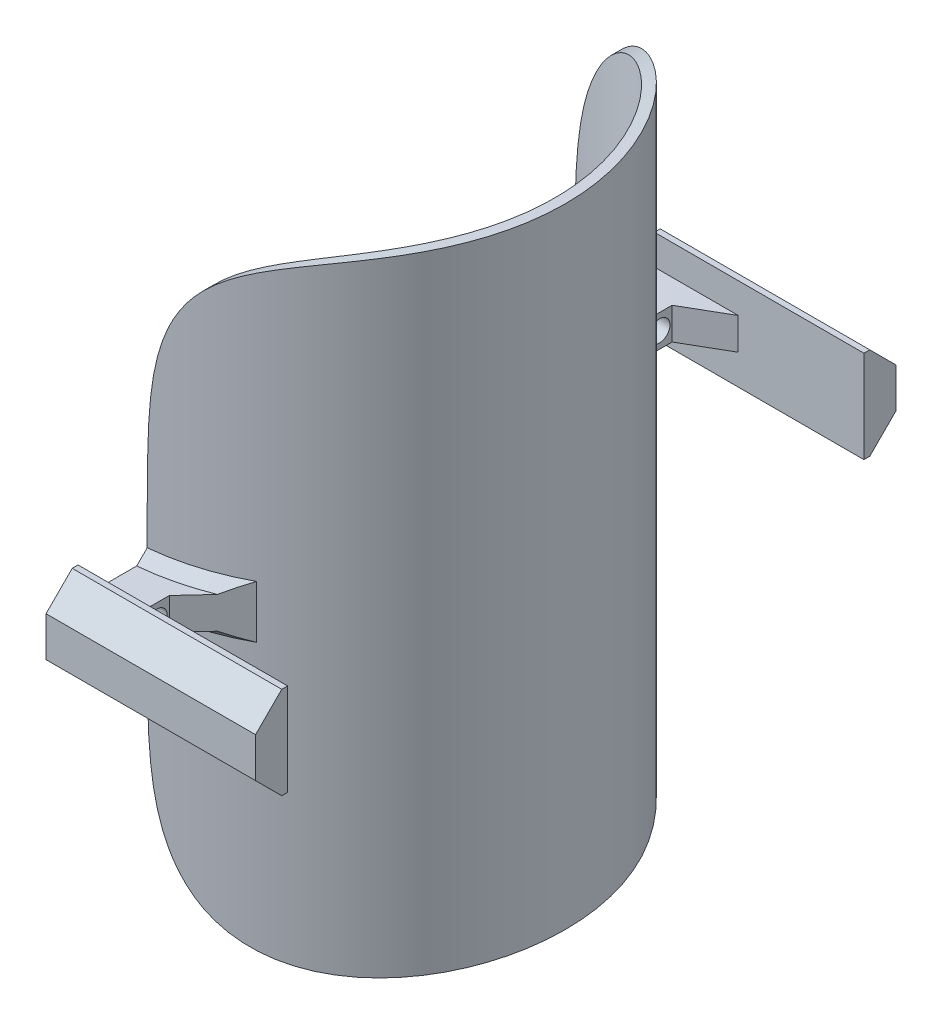
from build123d import *

# Parameters (mm, degrees)
SKETCH2_R                 = 52.5
SKETCH2_R_2               = 50
EXTRUDE_THIN1_DEPTH       = 75
CUT_EXTRUDE1_DEPTH        = 75
BOSS_EXTRUDE3_DEPTH       = 10
BOSS_EXTRUDE4_DEPTH       = 50
CHAMFER1_SIZE             = 10
CHAMFER1_SIZE2            = 5.773502691896273
CUT_EXTRUDE2_REACH        = 116.297
SKETCH9_R                 = 2.500000000000002
BOSS_EXTRUDE5_START       = -7.6
BOSS_EXTRUDE5_DEPTH       = 7.6
CHAMFER2_SIZE             = 2.5
CHAMFER1_OF_MIRROR1_SIZE2 = 5.773502691896273
CHAMFER1_OF_MIRROR1_SIZE  = 10
CHAMFER2_OF_MIRROR1_SIZE  = 2.5
CUT_EXTRUDE4_DEPTH        = 55


with BuildPart() as part:
    # Sketch2 → Extrude-Thin1 (new, symmetric)
    with BuildSketch(Plane(origin=(0, 0, 0), x_dir=(1, 0, 0), z_dir=(0, 1, 0))):
        Circle(SKETCH2_R)
        Circle(SKETCH2_R_2, mode=Mode.SUBTRACT)
    extrude(amount=EXTRUDE_THIN1_DEPTH, both=True)

    # Sketch3 → Cut-Extrude1 (cut, symmetric)
    with BuildSketch(Plane(origin=(0, 0, 0), x_dir=(1, 0, 0), z_dir=(0, 1, 0))):
        Polygon((4.999999999999993, 59.38113102411591), (5.000000000000009, -67.26797399217554), (-132.829326150241, 10.543220597022644), align=None)
    extrude(amount=CUT_EXTRUDE1_DEPTH, both=True, mode=Mode.SUBTRACT)

    # Sketch4 → Boss-Extrude3 (add)
    with BuildSketch(Plane.ZY.offset(-5)):
        Polygon((49.749371855331, 3.799999999999979), (49.749371855331, -3.7999999999999963), (52.261362400917186, -3.800000000000001), (68.76136240091718, -3.800000000000007), (68.76136240091718, 3.799999999999994), (52.261362400917186, 3.799999999999984), align=None)
    boss_extrude3 = extrude(amount=-BOSS_EXTRUDE3_DEPTH)

    # Sketch8 → Boss-Extrude4 (add)
    with BuildSketch(Plane.ZY.offset(-5)):
        Polygon((68.76136240091718, 10.999999999999995), (68.76136240091718, 3.799999999999994), (68.76136240091718, -3.800000000000007), (68.76136240091718, -11.000000000000009), (70.16136240091718, -11.000000000000007), (76.41136240091718, -4.750000000000007), (76.41136240091718, 4.7499999999999964), (70.16136240091718, 10.999999999999993), align=None)
    boss_extrude4 = extrude(amount=-BOSS_EXTRUDE4_DEPTH)

    # Chamfer1
    chamfer1_edges = [part.edges().sort_by_distance(p)[0] for p in [
        (15.000000000000009, -6.22e-15, 68.76136240091718),
    ]]
    chamfer1_side = [part.faces().sort_by_distance(p)[0] for p in [
        (31.48437500000001, -7.01e-15, 68.76136240091718),
    ]]
    chamfer(chamfer1_edges, length=CHAMFER1_SIZE, length2=CHAMFER1_SIZE2, reference=chamfer1_side[0])

    # Sketch9 → Cut-Extrude2 (cut, up to next)
    with BuildSketch(Plane(origin=(15, 0, -1.86e-15), x_dir=(-1.2e-16, 0, -1), z_dir=(1, 0, -1.2e-16)), mode=Mode.PRIVATE) as cut_extrude2_sk1:
        with Locations((-59.98785970902089, 0)):
            Circle(SKETCH9_R)
    cut_extrude2_tool1 = extrude(cut_extrude2_sk1.sketch, amount=-CUT_EXTRUDE2_REACH, mode=Mode.PRIVATE) & part.part
    cut_extrude2 = cut_extrude2_tool1.solids().sort_by_distance((15, 0, 59.98786))[0]
    add(cut_extrude2, mode=Mode.SUBTRACT)

    # Sketch10 → Boss-Extrude5 (add)
    with BuildSketch(Plane.XZ.offset(3.799999999999893).offset(BOSS_EXTRUDE5_START)):
        with BuildLine():
            Line((24.999999999999964, 46.1654632815485), (15.000000000000007, 56.98785970902091))
            Line((15.000000000000009, 56.98785970902091), (15.00000000000001, 50.311529493745276))
            ThreePointArc((15.000000000000021, 50.311529493745276), (20.10714963039217, 48.49693324057741), (24.99999999999998, 46.165463281548504))
        make_face()
    boss_extrude5 = extrude(amount=BOSS_EXTRUDE5_DEPTH)

    # Chamfer2
    chamfer2_edges = [part.edges().sort_by_distance(p)[0] for p in [
        (15.30653443854551, 3.800000000000107, 50.219119899512584),
        (15.306534438545505, -3.7999999999998963, 50.219119899512584),
    ]]
    chamfer(chamfer2_edges, length=CHAMFER2_SIZE)

    # Mirror1: Boss-Extrude3, Boss-Extrude4, Cut-Extrude2, Boss-Extrude5 across plane
    add(boss_extrude3.mirror(Plane.XY))
    add(boss_extrude4.mirror(Plane.XY))
    add(cut_extrude2.mirror(Plane.XY), mode=Mode.SUBTRACT)
    add(boss_extrude5.mirror(Plane.XY))

    # Chamfer1 of Mirror1
    chamfer1_of_mirror1_edges = [part.edges().sort_by_distance(p)[0] for p in [
        (15.000000000000009, -6.22e-15, -68.76136240091718),
    ]]
    chamfer(chamfer1_of_mirror1_edges, length=CHAMFER1_OF_MIRROR1_SIZE, length2=CHAMFER1_OF_MIRROR1_SIZE2)

    # Chamfer2 of Mirror1
    chamfer2_of_mirror1_edges = [part.edges().sort_by_distance(p)[0] for p in [
        (15.30653443854551, 3.800000000000107, -50.219119899512584),
        (15.306534438545505, -3.7999999999998963, -50.219119899512584),
    ]]
    chamfer(chamfer2_of_mirror1_edges, length=CHAMFER2_OF_MIRROR1_SIZE)

    # Sketch12 → Cut-Extrude4 (cut, symmetric)
    with BuildSketch(Plane.XY):
        with BuildLine():
            Line((5.000000000000006, 15), (5.000000000000006, 75))
            Line((5.000000000000006, 75), (52.50000000000001, 75))
            add(Edge.make_bspline(
                [(5.000000000000006, 15), (5.000000000000009, 32.56722451667293), (5.644874110491452, 59.48712745969903), (26.937651649578847, 74.99999999999999), (52.50000000000001, 75)],
                knots=[0, 0, 0, 0, 0.46185098317111584, 1, 1, 1, 1], degree=3))
        make_face()
    cut_extrude4 = extrude(amount=CUT_EXTRUDE4_DEPTH, both=True, mode=Mode.SUBTRACT)

    # Mirror4: Cut-Extrude4 across plane
    add(cut_extrude4.mirror(Plane.ZX), mode=Mode.SUBTRACT)


solid = part.part
